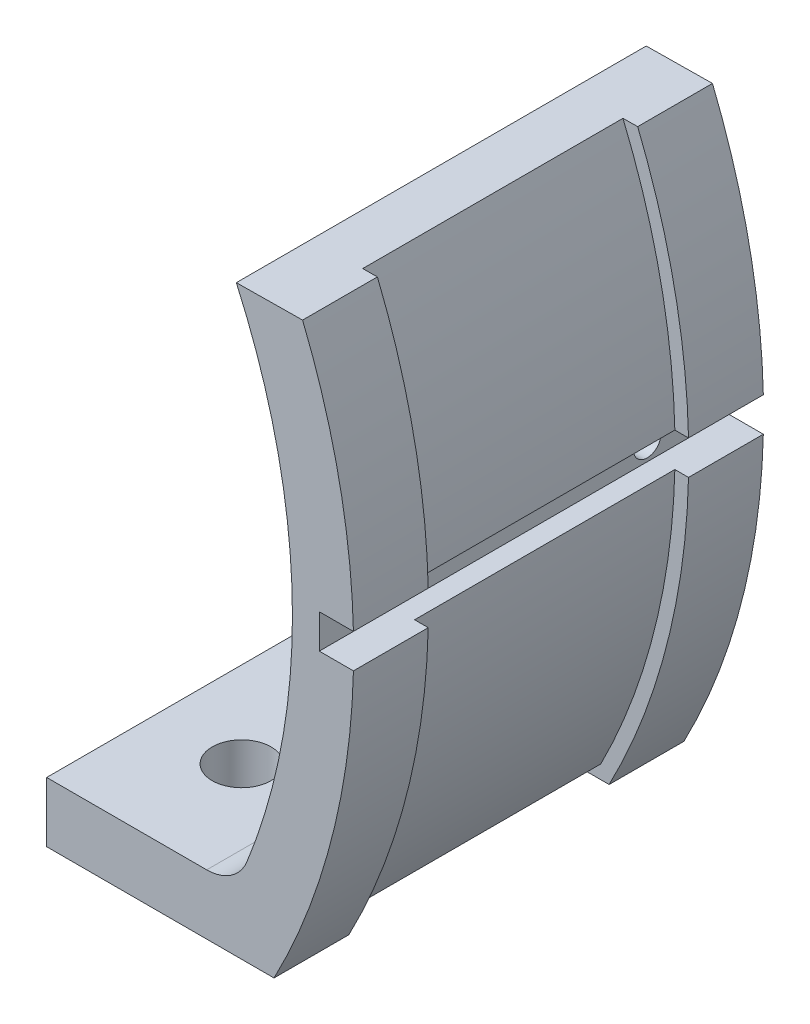
from build123d import *

# Parameters (mm, degrees)
EXTRUSION1_DEPTH   = 30
FILLET1_R          = 3.175
SKETCH2_R          = 1
EXTRUSION8_DEPTH   = 2
SKETCH3_R          = 2.15
EXTRUSION11_DEPTH  = 71.357498555
EXTRUSION12_DEPTH  = 9.525
CUT_EXTRUDE1_DEPTH = 1.27


with BuildPart() as part:
    # Sketch1 → Extrusion1 (new body)
    with BuildSketch(Plane.XY):
        with BuildLine():
            Line((47.06353616, 19.123444108), (42.213867638, 19.070033288))
            ThreePointArc((42.213867638, 19.070033288), (46.321150196, -0.088533061), (42.140232503, -19.23116511))
            Line((42.140232503, -19.23116511), (27.063632515, -19.23116511))
            Line((27.063632515, -19.23116511), (27.063633082, -22.12345478))
            Line((27.063633082, -22.12345478), (27.063633082, -23.62345478))
            Line((27.063633082, -23.62345478), (44.972996835, -23.62345478))
            ThreePointArc((44.972996835, -23.62345478), (49.168432062, -12.771632691), (50.784831526, -1.249871881))
            Line((50.784831526, -1.249871881), (48.284855505, -1.250061095))
            Line((48.284855505, -1.250061095), (48.284855505, 1.249938905))
            Line((48.284855505, 1.249938905), (50.784855505, 1.249938905))
            ThreePointArc((50.784855505, 1.249938905), (49.733715684, 10.355236056), (47.06353616, 19.123444108))
        make_face()
    extrude(amount=EXTRUSION1_DEPTH)

    # Fillet1
    fillet1_edges = [part.edges().sort_by_distance(p)[0] for p in [
        (42.140232503, -19.23116511, 15),
    ]]
    fillet(fillet1_edges, radius=FILLET1_R)

    # Sketch2 → Extrusion8 (cut)
    with BuildSketch(Plane(origin=(48.284855505, 0, 0), x_dir=(0, 0, -1), z_dir=(1, 0, 0))):
        with Locations(Location((-24, -6.1095e-05, 0), (0, 0, 90))):
            Circle(SKETCH2_R)
        with Locations(Location((-6, -6.1095e-05, 0), (0, 0, 90))):
            Circle(SKETCH2_R)
    extrude(amount=-EXTRUSION8_DEPTH, mode=Mode.SUBTRACT)

    # Sketch3 → Extrusion11 (cut, through all)
    with BuildSketch(Plane(origin=(0, -19.23116511, 0), x_dir=(-1, 0, 0), z_dir=(0, 1, 0))):
        with Locations((-34.601932509, 8)):
            Circle(SKETCH3_R)
        with Locations((-34.601932509, 22)):
            Circle(SKETCH3_R)
    extrude(amount=-EXTRUSION11_DEPTH, mode=Mode.SUBTRACT)

    # Sketch4 → Extrusion12 (cut, symmetric)
    with BuildSketch(Plane.XY.offset(15)):
        with BuildLine():
            Line((49.784318727, 1.249938905), (50.784855505, 1.249938905))
            ThreePointArc((50.784855505, 1.249938905), (49.733715684, 10.355236056), (47.06353616, 19.123444108))
            Line((47.06353616, 19.123444108), (45.987026195, 19.111588188))
            ThreePointArc((45.987026195, 19.111588188), (48.711366707, 10.356301793), (49.784318727, 1.249938905))
        make_face()
        with BuildLine():
            ThreePointArc((44.364346419, -22.62345478), (48.272126893, -12.240444134), (49.784292363, -1.249947608))
            Line((49.784292363, -1.249947608), (50.784831526, -1.249871881))
            ThreePointArc((50.784831526, -1.249871881), (49.168432062, -12.771632691), (44.972996835, -23.62345478))
            Line((44.972996835, -23.62345478), (27.063633082, -23.62345478))
            Line((27.063633082, -23.62345478), (27.063633082, -22.62345478))
            Line((27.063633082, -22.62345478), (44.364346419, -22.62345478))
        make_face()
    extrude(amount=EXTRUSION12_DEPTH, both=True, mode=Mode.SUBTRACT)

    # Sketch5 → Cut-Extrude1 (cut)
    with BuildSketch(Plane.ZY.offset(-27.063633082)):
        Polygon((0, -19.23116511), (0, -23.62345478), (5.475, -23.62345478), (5.475, -22.62345478), (24.525, -22.62345478), (24.525, -23.62345478), (30, -23.62345478), (30, -19.23116511), align=None)
    extrude(amount=-CUT_EXTRUDE1_DEPTH, mode=Mode.SUBTRACT)


with BuildPart() as cut_extrude1_kept_piece:
    # of the separate pieces the step leaves, the one the design keeps (cut_extrude1_pieces_kept)
    add(part.part.solids().sort_by_distance((42.99418243, -17.237727528, 0))[0])


solid = cut_extrude1_kept_piece.part
